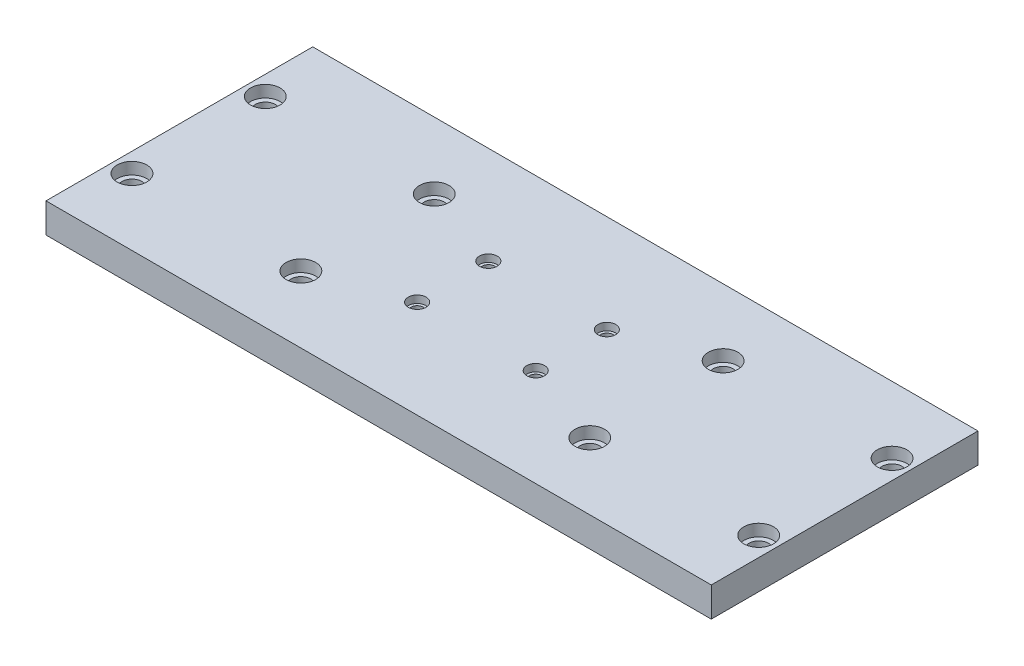
from build123d import *

# Parameters (mm, degrees)
CROQUIS1_W              = 224.48
CROQUIS1_H              = 90
SALIENTE_EXTRUIR1_DEPTH = 10
CROQUIS2_R              = 3.35
CORTAR_EXTRUIR1_DEPTH   = 11
CROQUIS22_R             = 2.1
CORTAR_EXTRUIR3_DEPTH   = 11
CROQUIS25_R             = 5
CORTAR_EXTRUIR4_DEPTH   = 4
CROQUIS26_R             = 3
CORTAR_EXTRUIR5_DEPTH   = 2.5
CROQUIS27_R             = 3.35
CORTAR_EXTRUIR6_DEPTH   = 11
CROQUIS28_R             = 5
CORTAR_EXTRUIR7_DEPTH   = 4


with BuildPart() as part:
    # Croquis1 → Saliente-Extruir1 (new body)
    with BuildSketch(Plane(origin=(0, 0, 0), x_dir=(1, 0, 0), z_dir=(0, 1, 0))):
        Rectangle(CROQUIS1_W, CROQUIS1_H)
    extrude(amount=SALIENTE_EXTRUIR1_DEPTH)

    # Croquis2 → Cortar-Extruir1 (cut, through all)
    with BuildSketch(Plane(origin=(0, 0, 0), x_dir=(1, 0, 0), z_dir=(0, 1, 0))):
        with Locations((-105.74, 22.5)):
            Circle(CROQUIS2_R)
        with Locations((105.74, 22.5)):
            Circle(CROQUIS2_R)
        with Locations((105.74, -22.5)):
            Circle(CROQUIS2_R)
        with Locations((-105.74, -22.5)):
            Circle(CROQUIS2_R)
    extrude(amount=CORTAR_EXTRUIR1_DEPTH, mode=Mode.SUBTRACT)

    # Croquis22 → Cortar-Extruir3 (cut, through all)
    with BuildSketch(Plane(origin=(0, 0, 0), x_dir=(1, 0, 0), z_dir=(0, 1, 0))):
        with Locations((20, 12)):
            Circle(CROQUIS22_R)
        with Locations((-20, 12)):
            Circle(CROQUIS22_R)
        with Locations((-20, -12)):
            Circle(CROQUIS22_R)
        with Locations((20, -12)):
            Circle(CROQUIS22_R)
    extrude(amount=CORTAR_EXTRUIR3_DEPTH, mode=Mode.SUBTRACT)

    # Croquis25 → Cortar-Extruir4 (cut)
    with BuildSketch(Plane(origin=(0, 10, 0), x_dir=(1, 0, 0), z_dir=(0, 1, 0))):
        with Locations((-105.74, 22.5)):
            Circle(CROQUIS25_R)
        with Locations((-105.74, -22.5)):
            Circle(CROQUIS25_R)
        with Locations((105.74, 22.5)):
            Circle(CROQUIS25_R)
        with Locations((105.74, -22.5)):
            Circle(CROQUIS25_R)
    extrude(amount=-CORTAR_EXTRUIR4_DEPTH, mode=Mode.SUBTRACT)

    # Croquis26 → Cortar-Extruir5 (cut)
    with BuildSketch(Plane(origin=(0, 10, 0), x_dir=(1, 0, 0), z_dir=(0, 1, 0))):
        with Locations((-20, 12)):
            Circle(CROQUIS26_R)
        with Locations((20, 12)):
            Circle(CROQUIS26_R)
        with Locations((20, -12)):
            Circle(CROQUIS26_R)
        with Locations((-20, -12)):
            Circle(CROQUIS26_R)
    extrude(amount=-CORTAR_EXTRUIR5_DEPTH, mode=Mode.SUBTRACT)

    # Croquis27 → Cortar-Extruir6 (cut, through all)
    with BuildSketch(Plane(origin=(0, 10, 0), x_dir=(1, 0, 0), z_dir=(0, 1, 0))):
        with Locations((-48.74, 22.5)):
            Circle(CROQUIS27_R)
        with Locations((48.74, 22.5)):
            Circle(CROQUIS27_R)
        with Locations((48.74, -22.5)):
            Circle(CROQUIS27_R)
        with Locations((-48.74, -22.5)):
            Circle(CROQUIS27_R)
    extrude(amount=-CORTAR_EXTRUIR6_DEPTH, mode=Mode.SUBTRACT)

    # Croquis28 → Cortar-Extruir7 (cut)
    with BuildSketch(Plane(origin=(0, 10, 0), x_dir=(1, 0, 0), z_dir=(0, 1, 0))):
        with Locations((-48.74, 22.5)):
            Circle(CROQUIS28_R)
        with Locations((-48.74, -22.5)):
            Circle(CROQUIS28_R)
        with Locations((48.74, -22.5)):
            Circle(CROQUIS28_R)
        with Locations((48.74, 22.5)):
            Circle(CROQUIS28_R)
    extrude(amount=-CORTAR_EXTRUIR7_DEPTH, mode=Mode.SUBTRACT)


solid = part.part
